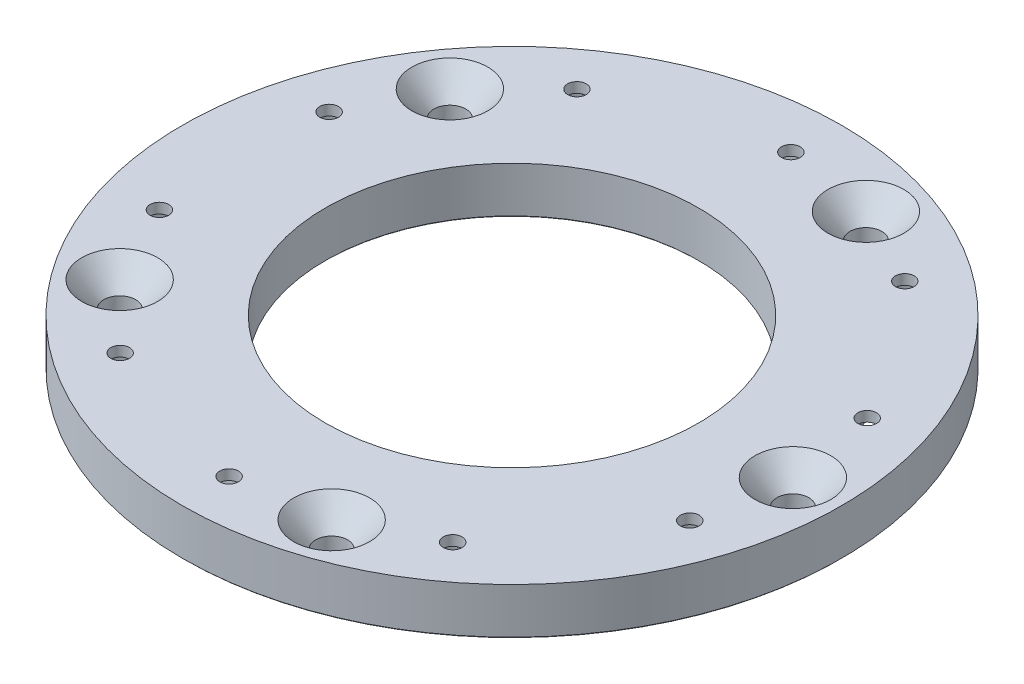
from build123d import *

# Parameters (mm, degrees)
CSK_FOR_1_4_FLAT_HEAD_MACHINE_SCREW1_D           = 5.4102
CSK_FOR_1_4_FLAT_HEAD_MACHINE_SCREW1_CSINK_D     = 12.8778
CSK_FOR_1_4_FLAT_HEAD_MACHINE_SCREW1_CSINK_ANGLE = 82
SKETCH5_R                                        = 1.5875
RIVET_HOLES_DEPTH                                = 8.9375
CUT_EXTRUDE2_DEPTH                               = 6.2103
CHAMFER1_SIZE                                    = 0.2032


with BuildPart() as part:
    # Sketch1 → Revolve1 (revolve)
    with BuildSketch(Plane.XY):
        Polygon((31.623, 0), (31.623, -7.9375), (34.163, -7.9375), (34.163, -3.9497), (41.275, -3.9497), (41.275, -7.9375), (55.88, -7.9375), (55.88, 0), align=None)
    revolve(axis=Axis((0, 29.876386318, 0), (0, -1, 0)))

    # CSK for 1/4 Flat Head Machine Screw1 (through all)
    with Locations(Plane(origin=(0, 0, 0), x_dir=(-1, 0, 0), z_dir=(0, 1, 0))):
        with Locations((-47.625, 0), (-14.716934357, 45.294066589), (38.529434357, 27.99327264), (38.529434357, -27.99327264), (-14.716934357, -45.294066589)):
            CounterSinkHole(CSK_FOR_1_4_FLAT_HEAD_MACHINE_SCREW1_D / 2, CSK_FOR_1_4_FLAT_HEAD_MACHINE_SCREW1_CSINK_D / 2, counter_sink_angle=CSK_FOR_1_4_FLAT_HEAD_MACHINE_SCREW1_CSINK_ANGLE)

    # Sketch5 → Rivet Holes (cut, through all)
    with BuildSketch(Plane(origin=(0, 0, 0), x_dir=(1, 0, 0), z_dir=(0, 1, 0))):
        with Locations((-27.714283891, 38.730596347)):
            Circle(SKETCH5_R)
        with Locations((-0.343946691, 47.623757996)):
            Circle(SKETCH5_R)
        with Locations((28.270801327, 38.326262762)):
            Circle(SKETCH5_R)
        with Locations((45.1866, 15.043663299)):
            Circle(SKETCH5_R)
        with Locations((45.1866, -15.043663299)):
            Circle(SKETCH5_R)
        with Locations((28.270801327, -38.326262762)):
            Circle(SKETCH5_R)
        with Locations((-0.343946691, -47.623757996)):
            Circle(SKETCH5_R)
        with Locations((-27.714283891, -38.730596347)):
            Circle(SKETCH5_R)
        with Locations((-45.399170745, -14.389437815)):
            Circle(SKETCH5_R)
        with Locations((-45.399170745, 14.389437815)):
            Circle(SKETCH5_R)
    extrude(amount=-RIVET_HOLES_DEPTH, mode=Mode.SUBTRACT)

    # Sketch6 → Cut-Extrude2 (cut)
    with BuildSketch(Plane.XZ.offset(7.9375)):
        with BuildLine():
            ThreePointArc((48.95215, 16.297301907), (41.740220554, 30.32604536), (30.626701438, 41.520117993))
            ThreePointArc((30.626701438, 41.520117993), (25.076946097, 40.682162873), (25.914901216, 35.132407532))
            ThreePointArc((25.914901216, 35.132407532), (35.318648161, 25.66049992), (41.42105, 13.79002469))
            ThreePointArc((41.42105, 13.79002469), (46.440238608, 11.278113299), (48.95215, 16.297301907))
        make_face()
        with BuildLine():
            ThreePointArc((-0.372608915, 51.592404496), (-15.943345554, 49.068572138), (-30.023807548, 41.958146043))
            ThreePointArc((-30.023807548, 41.958146043), (-30.941833586, 36.42107269), (-25.404760233, 35.503046652))
            ThreePointArc((-25.404760233, 35.503046652), (-13.490523161, 41.51956104), (-0.315284467, 43.655111496))
            ThreePointArc((-0.315284467, 43.655111496), (3.624699809, 47.65242022), (-0.372608915, 51.592404496))
        make_face()
        with BuildLine():
            ThreePointArc((-49.182434974, 15.588557633), (-51.59375, 0), (-49.182434974, -15.588557633))
            ThreePointArc((-49.182434974, -15.588557633), (-44.200050927, -18.172702044), (-41.615906517, -13.190317997))
            ThreePointArc((-41.615906517, -13.190317997), (-43.65625, 0), (-41.615906517, 13.190317997))
            ThreePointArc((-41.615906517, 13.190317997), (-44.200050927, 18.172702044), (-49.182434974, 15.588557633))
        make_face()
        with BuildLine():
            ThreePointArc((-30.023807548, -41.958146043), (-15.943345554, -49.068572138), (-0.372608915, -51.592404496))
            ThreePointArc((-0.372608915, -51.592404496), (3.624699809, -47.65242022), (-0.315284467, -43.655111496))
            ThreePointArc((-0.315284467, -43.655111496), (-13.490523161, -41.51956104), (-25.404760233, -35.503046652))
            ThreePointArc((-25.404760233, -35.503046652), (-30.941833586, -36.42107269), (-30.023807548, -41.958146043))
        make_face()
        with BuildLine():
            ThreePointArc((30.626701438, -41.520117993), (41.740220554, -30.32604536), (48.95215, -16.297301907))
            ThreePointArc((48.95215, -16.297301907), (46.440238608, -11.278113299), (41.42105, -13.79002469))
            ThreePointArc((41.42105, -13.79002469), (35.318648161, -25.66049992), (25.914901216, -35.132407532))
            ThreePointArc((25.914901216, -35.132407532), (25.076946097, -40.682162873), (30.626701438, -41.520117993))
        make_face()
    extrude(amount=-CUT_EXTRUDE2_DEPTH, mode=Mode.SUBTRACT)

    # Chamfer1
    chamfer1_edges = [part.edges().sort_by_distance(p)[0] for p in [
        (-31.623, -7.9375, 0),
        (-55.88, -7.9375, 0),
        (-41.275, -7.9375, 0),
        (-34.163, -7.9375, 0),
    ]]
    chamfer(chamfer1_edges, length=CHAMFER1_SIZE)


solid = part.part
